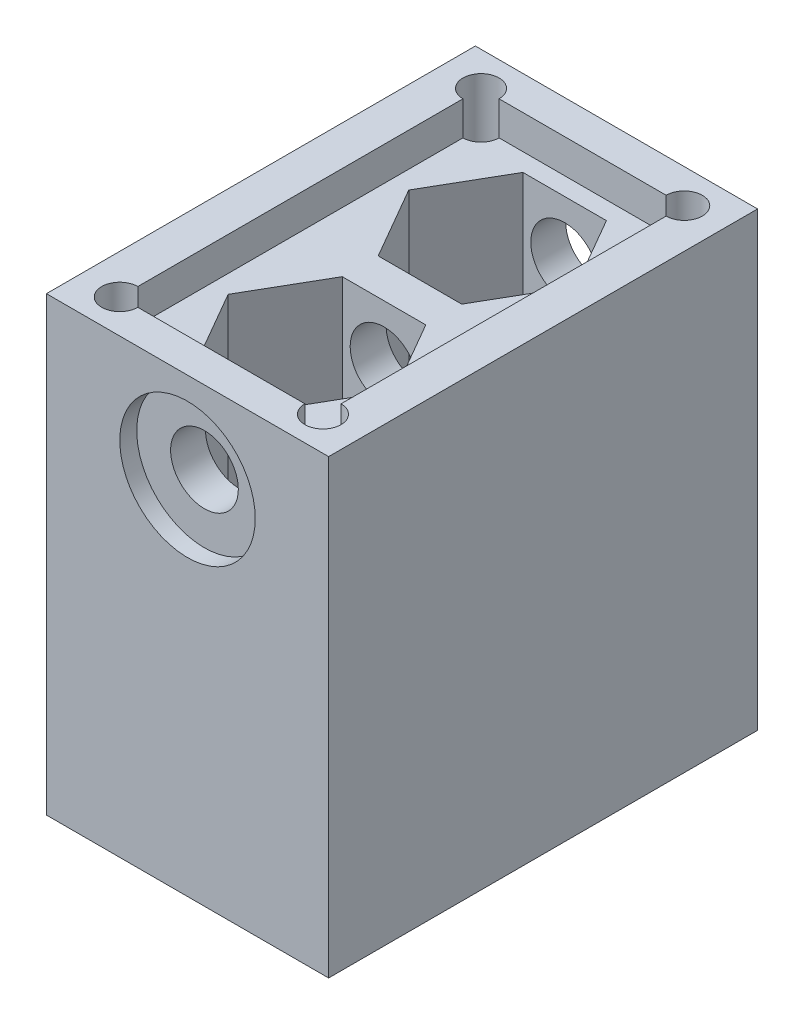
from build123d import *

# Parameters (mm, degrees)
SKETCH1_W           = 25
SKETCH1_H           = 38
BOSS_EXTRUDE1_DEPTH = 40
SKETCH2_R           = 3
CUT_EXTRUDE1_DEPTH  = 39
SKETCH4_R           = 4.15
CUT_EXTRUDE2_DEPTH  = 41
CUT_EXTRUDE3_DEPTH  = 18
SKETCH6_R           = 1.6
CUT_EXTRUDE4_DEPTH  = 41
SKETCH7_W           = 18
SKETCH7_H           = 32
CUT_EXTRUDE5_DEPTH  = 3
SKETCH9_R           = 6
CUT_EXTRUDE6_DEPTH  = 1.5
SKETCH10_R          = 6
CUT_EXTRUDE7_DEPTH  = 1.5


with BuildPart() as part:
    # Sketch1 → Boss-Extrude1 (new body)
    with BuildSketch(Plane(origin=(0, 0, 0), x_dir=(1, 0, 0), z_dir=(0, 1, 0))):
        Rectangle(SKETCH1_W, SKETCH1_H)
    extrude(amount=BOSS_EXTRUDE1_DEPTH)

    # Sketch2 → Cut-Extrude1 (cut, through all)
    with BuildSketch(Plane.XY.offset(19)):
        with Locations((0, 32)):
            Circle(SKETCH2_R)
    extrude(amount=-CUT_EXTRUDE1_DEPTH, mode=Mode.SUBTRACT)

    # Sketch4 → Cut-Extrude2 (cut, through all)
    with BuildSketch(Plane(origin=(0, 40, 0), x_dir=(1, 0, 0), z_dir=(0, 1, 0))):
        with Locations((0, -8)):
            Circle(SKETCH4_R)
        with Locations((0, 8)):
            Circle(SKETCH4_R)
    extrude(amount=-CUT_EXTRUDE2_DEPTH, mode=Mode.SUBTRACT)

    # Sketch5 → Cut-Extrude3 (cut)
    with BuildSketch(Plane(origin=(0, 40, 0), x_dir=(1, 0, 0), z_dir=(0, 1, 0))):
        Polygon((-3.7, -14.408587988), (3.7, -14.408587988), (7.4, -8), (3.7, -1.591412012), (-3.7, -1.591412012), (-7.4, -8), align=None)
        Polygon((-3.7, 14.408587988), (-7.4, 8), (-3.7, 1.591412012), (3.7, 1.591412012), (7.4, 8), (3.7, 14.408587988), align=None)
    extrude(amount=-CUT_EXTRUDE3_DEPTH, mode=Mode.SUBTRACT)

    # Sketch6 → Cut-Extrude4 (cut, through all)
    with BuildSketch(Plane(origin=(0, 40, 0), x_dir=(1, 0, 0), z_dir=(0, 1, 0))):
        with Locations((9, -16)):
            Circle(SKETCH6_R)
        with Locations((-9, -16)):
            Circle(SKETCH6_R)
        with Locations((-9, 16)):
            Circle(SKETCH6_R)
        with Locations((9, 16)):
            Circle(SKETCH6_R)
    extrude(amount=-CUT_EXTRUDE4_DEPTH, mode=Mode.SUBTRACT)

    # Sketch7 → Cut-Extrude5 (cut)
    with BuildSketch(Plane(origin=(0, 40, 0), x_dir=(1, 0, 0), z_dir=(0, 1, 0))):
        Rectangle(SKETCH7_W, SKETCH7_H)
    extrude(amount=-CUT_EXTRUDE5_DEPTH, mode=Mode.SUBTRACT)

    # Sketch9 → Cut-Extrude6 (cut)
    with BuildSketch(Plane(origin=(0, 0, -19), x_dir=(-1, 0, 0), z_dir=(0, 0, -1))):
        with Locations((0, 32)):
            Circle(SKETCH9_R)
    extrude(amount=-CUT_EXTRUDE6_DEPTH, mode=Mode.SUBTRACT)

    # Sketch10 → Cut-Extrude7 (cut)
    with BuildSketch(Plane.XY.offset(19)):
        with Locations((0, 32)):
            Circle(SKETCH10_R)
    extrude(amount=-CUT_EXTRUDE7_DEPTH, mode=Mode.SUBTRACT)


solid = part.part
